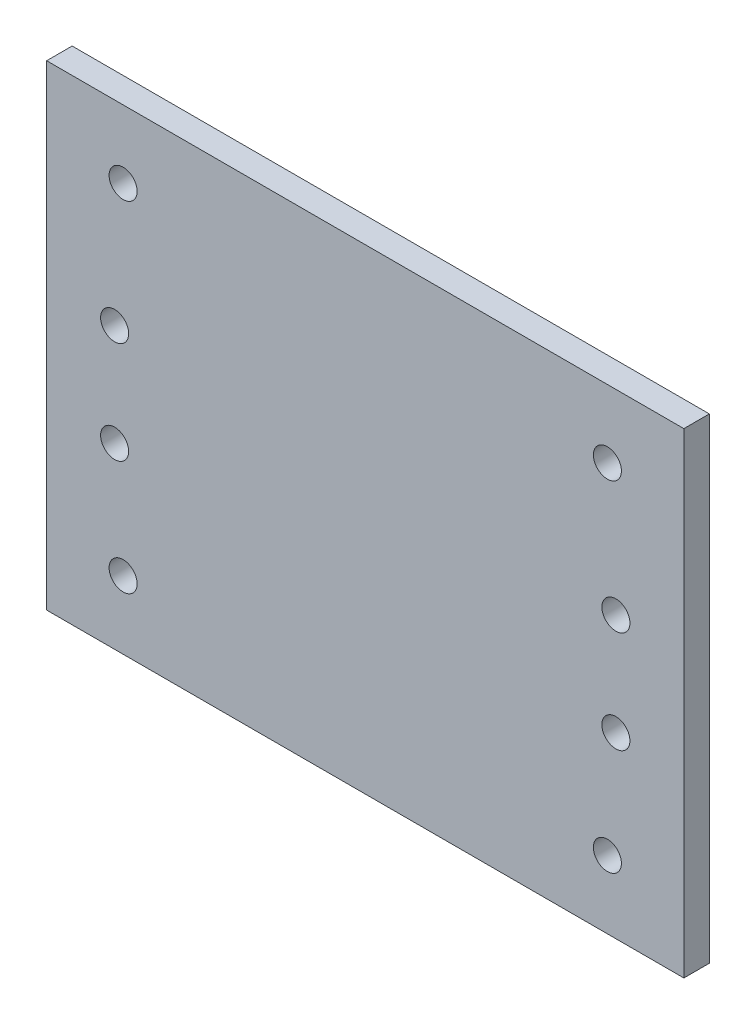
from build123d import *

# Parameters (mm, degrees)
SKETCH_1_W          = 75
SKETCH_1_H          = 56
EXTRUDE_1_DEPTH     = 3
SKETCH_2_R          = 1.65
CUT_EXTRUDE_1_DEPTH = 3
SKETCH_4_R          = 1.65
CUT_EXTRUDE_3_DEPTH = 8


with BuildPart() as part:
    # 草图1 → 凸台-拉伸1 (new body)
    with BuildSketch(Plane.XY):
        Rectangle(SKETCH_1_W, SKETCH_1_H)
    extrude(amount=EXTRUDE_1_DEPTH)

    # 草图2 → 切除-拉伸1 (cut)
    with BuildSketch(Plane(origin=(0, 0, 0), x_dir=(-1, 0, 0), z_dir=(0, 0, -1))):
        with Locations((-28.5, 20)):
            Circle(SKETCH_2_R)
        with Locations((28.5, 20)):
            Circle(SKETCH_2_R)
        with Locations((-28.5, -20)):
            Circle(SKETCH_2_R)
        with Locations((28.5, -20)):
            Circle(SKETCH_2_R)
    extrude(amount=-CUT_EXTRUDE_1_DEPTH, mode=Mode.SUBTRACT)

    # 草图4 → 切除-拉伸3 (cut)
    with BuildSketch(Plane(origin=(0, 0, 0), x_dir=(-1, 0, 0), z_dir=(0, 0, -1))):
        with Locations((-29.5, 5)):
            Circle(SKETCH_4_R)
        with Locations((29.5, 5)):
            Circle(SKETCH_4_R)
        with Locations((-29.5, -7)):
            Circle(SKETCH_4_R)
        with Locations((29.5, -7)):
            Circle(SKETCH_4_R)
    extrude(amount=-CUT_EXTRUDE_3_DEPTH, mode=Mode.SUBTRACT)


solid = part.part
